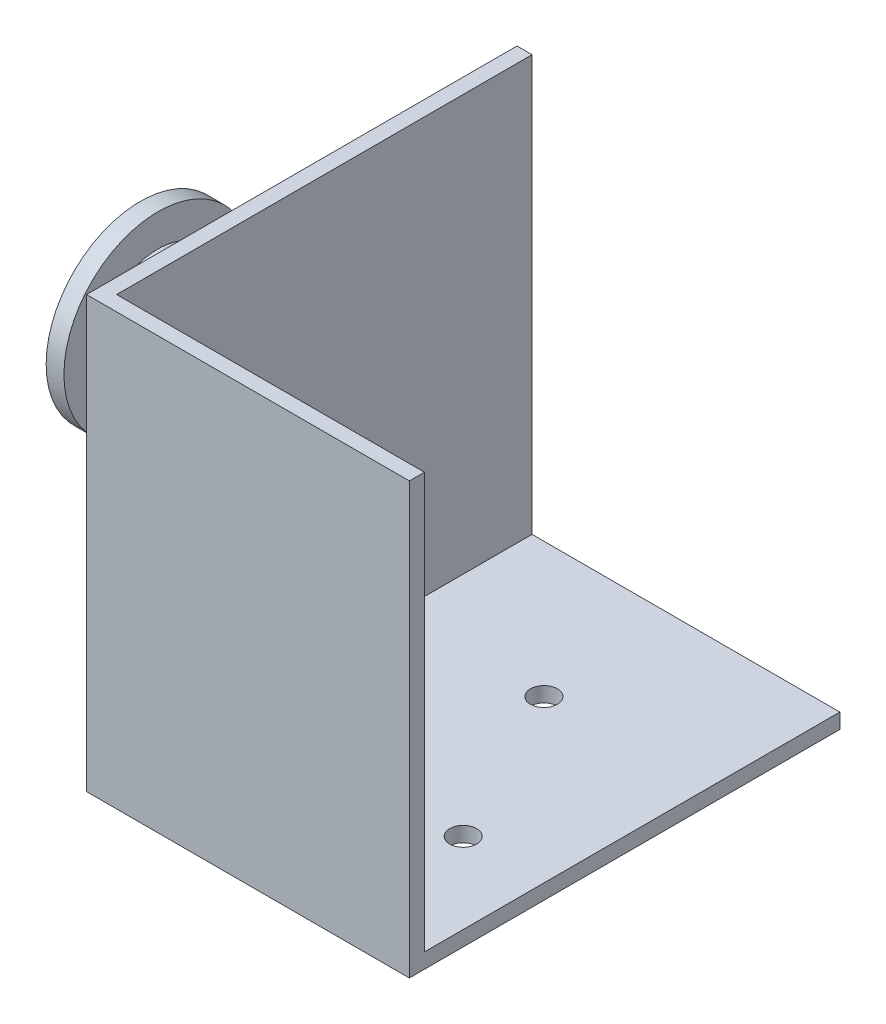
from build123d import *

# Parameters (mm, degrees)
SKETCH1_W           = 30.48
SKETCH1_H           = 40.64
BOSS_EXTRUDE1_DEPTH = 20.32
SKETCH2_W           = 39.2176
SKETCH2_H           = 39.2176
CUT_EXTRUDE1_DEPTH  = 29.0576
SKETCH3_R           = 1.27
CUT_EXTRUDE2_DEPTH  = 2.4224
SKETCH4_R           = 3.81
BOSS_EXTRUDE2_DEPTH = 19.05
FILLET1_R           = 2.54


with BuildPart() as part:
    # Sketch1 → Boss-Extrude1 (new body, symmetric)
    with BuildSketch(Plane(origin=(0, 0, 0), x_dir=(1, 0, 0), z_dir=(0, 1, 0))):
        Rectangle(SKETCH1_W, SKETCH1_H)
    extrude(amount=BOSS_EXTRUDE1_DEPTH, both=True)

    # Sketch2 → Cut-Extrude1 (cut)
    with BuildSketch(Plane(origin=(15.24, 0, 0), x_dir=(0, 0, -1), z_dir=(1, 0, 0))):
        with Locations((0.7112, 0.7112)):
            Rectangle(SKETCH2_W, SKETCH2_H)
    extrude(amount=-CUT_EXTRUDE1_DEPTH, mode=Mode.SUBTRACT)

    # Sketch3 → Cut-Extrude2 (cut, through all)
    with BuildSketch(Plane(origin=(0, -18.8976, 0), x_dir=(1, 0, 0), z_dir=(0, 1, 0))):
        with Locations((-5.08, -7.62)):
            Circle(SKETCH3_R)
        with Locations((7.62, -7.62)):
            Circle(SKETCH3_R)
        with Locations((0, 7.62)):
            Circle(SKETCH3_R)
    extrude(amount=-CUT_EXTRUDE2_DEPTH, mode=Mode.SUBTRACT)

    # Sketch4 → Boss-Extrude2 (add)
    with BuildSketch(Plane.ZY.offset(15.24)):
        with Locations((0, 1.27)):
            Circle(SKETCH4_R)
    extrude(amount=BOSS_EXTRUDE2_DEPTH)

    # Sketch5 → Revolve1 (revolve)
    with BuildSketch(Plane.XY):
        Polygon((-30.48, 5.08), (-30.48, 10.16), (-28.8036, 10.16), (-28.8036, 7.112), (-21.8186, 7.112), (-21.8186, 10.16), (-20.1422, 10.16), (-20.1422, 5.08), align=None)
    revolve(axis=Axis((-34.29, 1.27, 0), (1, 0, 0)))

    # Fillet1
    fillet1_edges = [part.edges().sort_by_distance(p)[0] for p in [
        (-34.29, 1.27, -3.81),
    ]]
    fillet(fillet1_edges, radius=FILLET1_R)


solid = part.part
